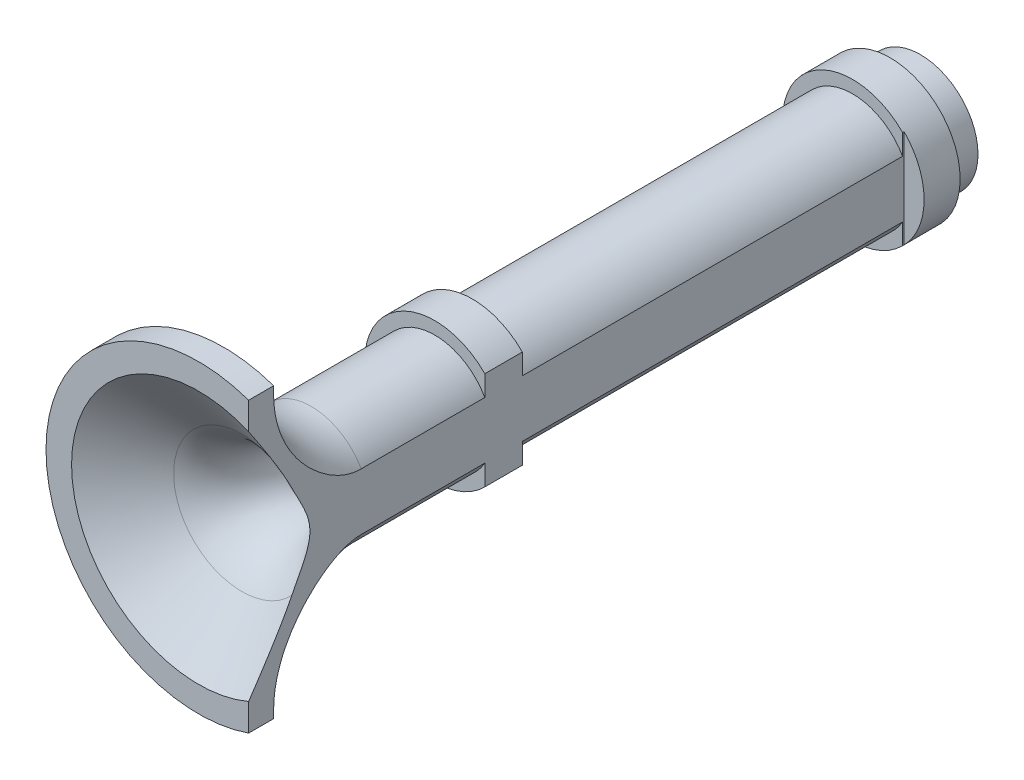
from build123d import *

# Parameters (mm, degrees)
CUT_EXTRUDE1_DEPTH = 26.2


with BuildPart() as part:
    # Sketch1 → Revolve1 (revolve)
    with BuildSketch(Plane(origin=(0, 0, 0), x_dir=(0, 0, -1), z_dir=(1, 0, 0))):
        with BuildLine():
            Line((0, 5.078211692), (0, 6.1))
            Line((0, 6.1), (1, 6.1))
            Line((1, 6.1), (1, 5.8))
            ThreePointArc((1, 5.8), (2.025126266, 3.325126266), (4.5, 2.3))
            Line((4.5, 2.3), (9.440083729, 2.3))
            Line((9.440083729, 2.3), (9.440083729, 2.8))
            Line((9.440083729, 2.8), (10.940083729, 2.8))
            Line((10.940083729, 2.8), (10.940083729, 2.3))
            Line((10.940083729, 2.3), (26.140083729, 2.3))
            Line((26.140083729, 2.3), (26.140083729, 2.8))
            Line((26.140083729, 2.8), (27.640083729, 2.8))
            Line((27.640083729, 2.8), (27.640083729, 2.3))
            Line((27.640083729, 2.3), (28.853856016, 2.3))
            Line((28.853856016, 2.3), (28.853856016, 1.3))
            Line((28.853856016, 1.3), (4.548739728, 1.3))
            ThreePointArc((4.548739728, 1.3), (2.968613199, 1.676988608), (1.728880785, 2.72674277))
            Line((1.728880785, 2.72674277), (0, 5.078211692))
        make_face()
    revolve(axis=Axis((0, 0, 0), (0, 0, -1)))

    # Sketch2 → Cut-Extrude1 (cut)
    with BuildSketch(Plane.XY):
        Polygon((2, 6), (2, -6.569031419), (7.819181693, -6.569031419), (7.708002274, 5.9580813), align=None)
    extrude(amount=-CUT_EXTRUDE1_DEPTH, mode=Mode.SUBTRACT)


solid = part.part
